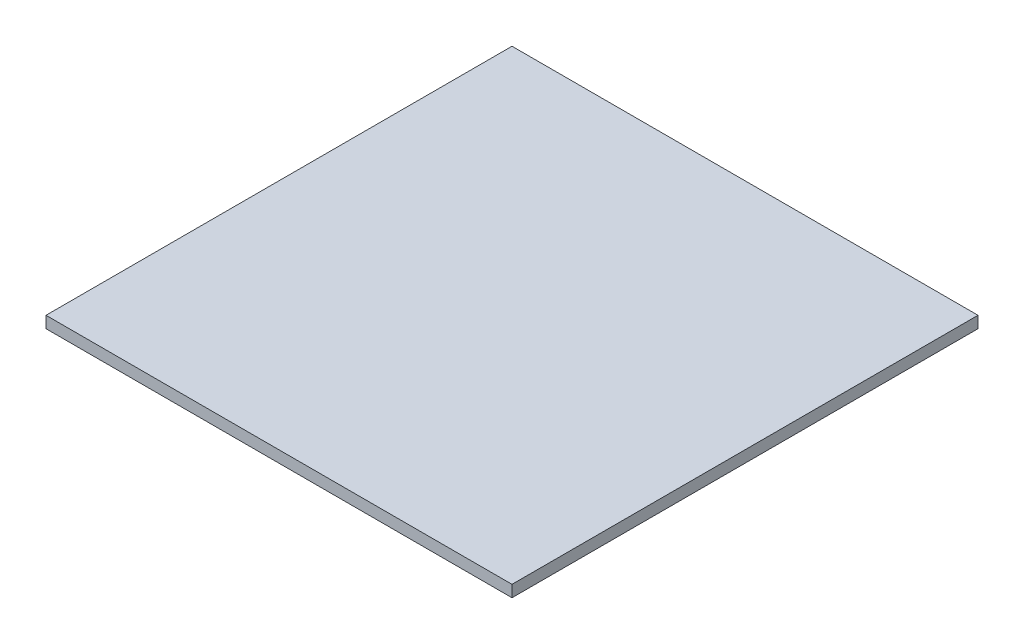
from build123d import *

# Parameters (mm, degrees)
SKETCH_1_W      = 50
SKETCH_1_H      = 50
EXTRUDE_1_DEPTH = 1.25


with BuildPart() as part:
    # 草图1 → 凸台-拉伸1 (new body)
    with BuildSketch(Plane(origin=(0, 0, 0), x_dir=(1, 0, 0), z_dir=(0, 1, 0))):
        Rectangle(SKETCH_1_W, SKETCH_1_H)
    extrude(amount=EXTRUDE_1_DEPTH)


solid = part.part
